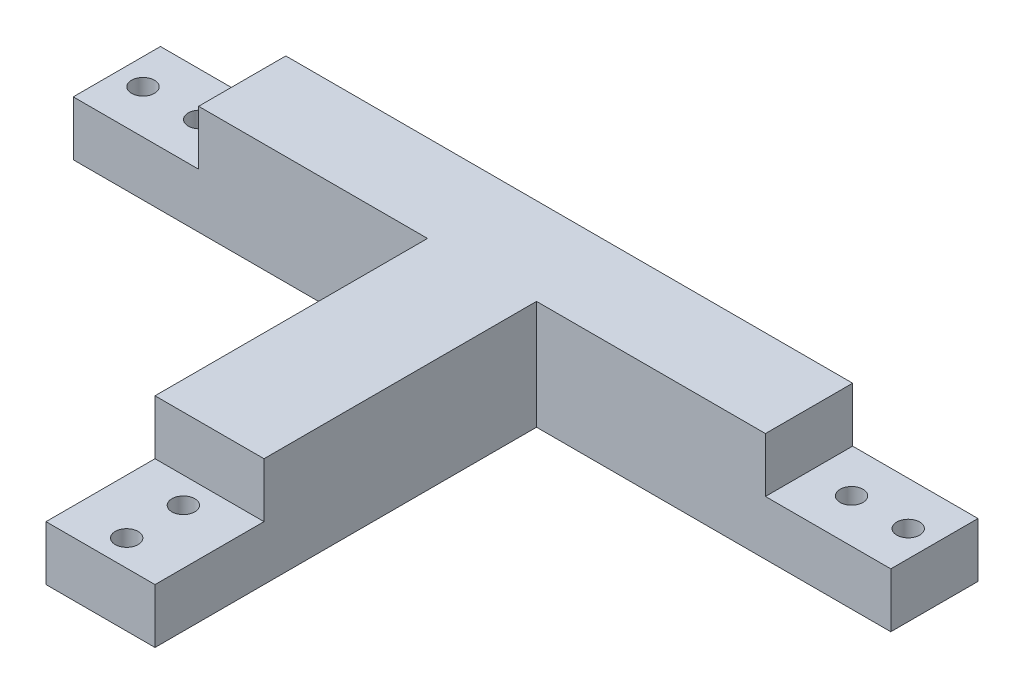
from build123d import *

# Parameters (mm, degrees)
SKETCH_1_W          = 150
SKETCH_1_H          = 16
EXTRUDE_1_DEPTH     = 10
SKETCH_2_W          = 110
SKETCH_2_H          = 16
EXTRUDE_2_DEPTH     = 10
SKETCH_4_R          = 2.1
CUT_EXTRUDE_1_DEPTH = 10
SKETCH_5_R          = 2.1
CUT_EXTRUDE_2_DEPTH = 10
SKETCH_6_W          = 20
SKETCH_6_H          = 20
EXTRUDE_3_DEPTH     = 50
SKETCH_7_W          = 20
SKETCH_7_H          = 10
EXTRUDE_4_DEPTH     = 20
SKETCH_8_R          = 2.1
CUT_EXTRUDE_3_DEPTH = 10
SKETCH_9_W          = 3
SKETCH_9_H          = 16
CUT_EXTRUDE_4_DEPTH = 10


with BuildPart() as part:
    # 草图1 → 凸台-拉伸1 (new body)
    with BuildSketch(Plane(origin=(0, 0, 0), x_dir=(1, 0, 0), z_dir=(0, 1, 0))):
        Rectangle(SKETCH_1_W, SKETCH_1_H)
    extrude(amount=EXTRUDE_1_DEPTH)

    # 草图2 → 凸台-拉伸2 (add)
    with BuildSketch(Plane(origin=(0, 10, 0), x_dir=(1, 0, 0), z_dir=(0, 1, 0))):
        Rectangle(SKETCH_2_W, SKETCH_2_H)
    extrude(amount=EXTRUDE_2_DEPTH)

    # 草图4 → 切除-拉伸1 (cut)
    with BuildSketch(Plane(origin=(0, 10, 0), x_dir=(1, 0, 0), z_dir=(0, 1, 0))):
        with Locations((-70.2, 0)):
            Circle(SKETCH_4_R)
        with Locations((-59.8, 0)):
            Circle(SKETCH_4_R)
    extrude(amount=-CUT_EXTRUDE_1_DEPTH, mode=Mode.SUBTRACT)

    # 草图5 → 切除-拉伸2 (cut)
    with BuildSketch(Plane(origin=(0, 10, 0), x_dir=(1, 0, 0), z_dir=(0, 1, 0))):
        with Locations((59.8, 0)):
            Circle(SKETCH_5_R)
        with Locations((70.2, 0)):
            Circle(SKETCH_5_R)
    extrude(amount=-CUT_EXTRUDE_2_DEPTH, mode=Mode.SUBTRACT)

    # 草图6 → 凸台-拉伸3 (add)
    with BuildSketch(Plane.XY.offset(8)):
        with Locations((0, 10)):
            Rectangle(SKETCH_6_W, SKETCH_6_H)
    extrude(amount=EXTRUDE_3_DEPTH)

    # 草图7 → 凸台-拉伸4 (add)
    with BuildSketch(Plane.XY.offset(58)):
        with Locations((0, 5)):
            Rectangle(SKETCH_7_W, SKETCH_7_H)
    extrude(amount=EXTRUDE_4_DEPTH)

    # 草图8 → 切除-拉伸3 (cut)
    with BuildSketch(Plane(origin=(0, 10, 0), x_dir=(1, 0, 0), z_dir=(0, 1, 0))):
        with Locations((0, -62.8)):
            Circle(SKETCH_8_R)
        with Locations((0, -73.2)):
            Circle(SKETCH_8_R)
    extrude(amount=-CUT_EXTRUDE_3_DEPTH, mode=Mode.SUBTRACT)

    # 草图9 → 切除-拉伸4 (cut)
    with BuildSketch(Plane(origin=(0, 20, 0), x_dir=(1, 0, 0), z_dir=(0, 1, 0))):
        with Locations((-53.5, 0)):
            Rectangle(SKETCH_9_W, SKETCH_9_H)
        with Locations((53.5, 0)):
            Rectangle(SKETCH_9_W, SKETCH_9_H)
    extrude(amount=-CUT_EXTRUDE_4_DEPTH, mode=Mode.SUBTRACT)


solid = part.part
